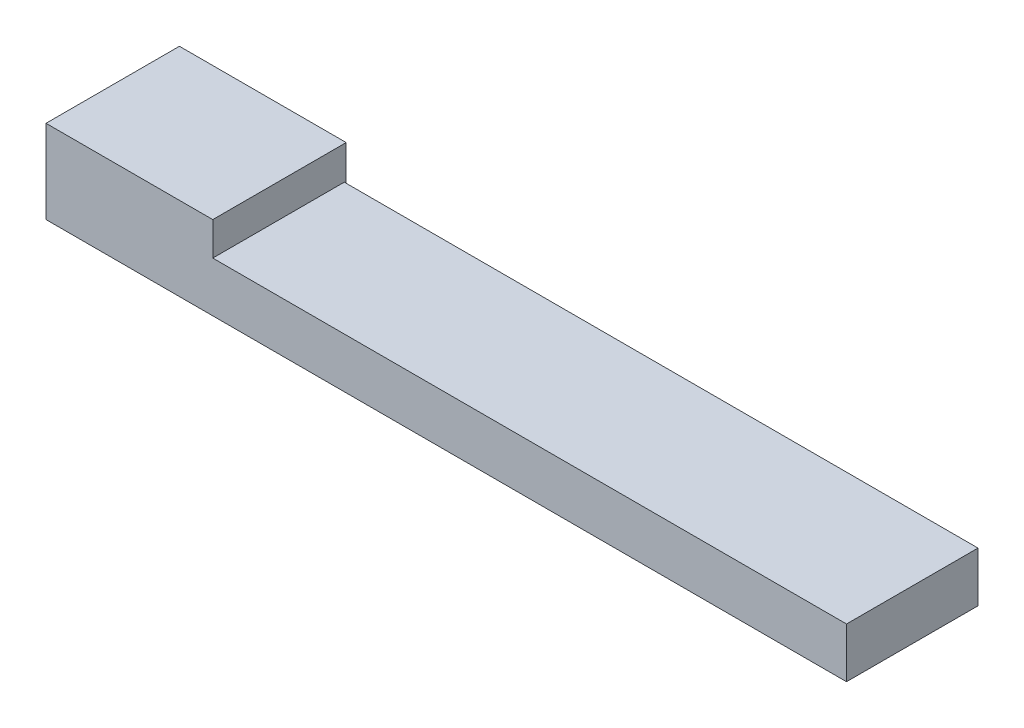
from build123d import *

# Parameters (mm, degrees)
SKETCH1_W           = 3048
SKETCH1_H           = 2438.4
BOSS_EXTRUDE1_DEPTH = 1524
SKETCH3_W           = 11582.4
SKETCH3_H           = 2403.091922187
BOSS_EXTRUDE2_DEPTH = 914.4


with BuildPart() as part:
    # Sketch1 → Boss-Extrude1 (new body)
    with BuildSketch(Plane(origin=(0, 0, 0), x_dir=(1, 0, 0), z_dir=(0, 1, 0))):
        with Locations((1461.775569056, 1156.389927353)):
            Rectangle(SKETCH1_W, SKETCH1_H)
    extrude(amount=BOSS_EXTRUDE1_DEPTH)

    # Sketch3 → Boss-Extrude2 (add)
    with BuildSketch(Plane.XZ):
        with Locations((8776.975569056, -1138.735888446)):
            Rectangle(SKETCH3_W, SKETCH3_H)
    extrude(amount=-BOSS_EXTRUDE2_DEPTH)


solid = part.part
